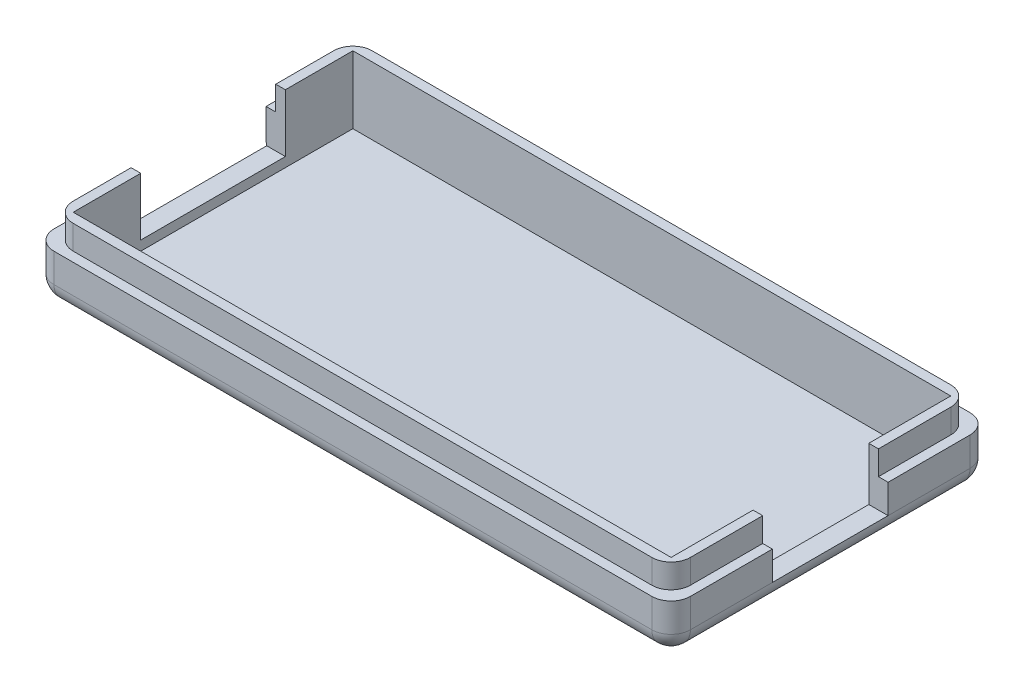
from build123d import *

# Parameters (mm, degrees)
SKETCH1_W           = 66
SKETCH1_H           = 33
BOSS_EXTRUDE1_DEPTH = 5
SKETCH2_W           = 64
SKETCH2_H           = 31
BOSS_EXTRUDE2_DEPTH = 2.5
SKETCH3_W           = 62
SKETCH3_H           = 29
CUT_EXTRUDE1_DEPTH  = 7
FILLET1_R           = 2
FILLET2_R           = 2
SKETCH4_W           = 12
SKETCH4_H           = 2.5
CUT_EXTRUDE2_DEPTH  = 7
SKETCH10_W          = 12
SKETCH10_H          = 3
CUT_EXTRUDE3_DEPTH  = 7
SKETCH11_W          = 15
SKETCH11_H          = 2.5
CUT_EXTRUDE4_DEPTH  = 7
SKETCH12_W          = 15
SKETCH12_H          = 3.5
CUT_EXTRUDE5_DEPTH  = 7


with BuildPart() as part:
    # Sketch1 → Boss-Extrude1 (new body)
    with BuildSketch(Plane(origin=(0, 0, 0), x_dir=(1, 0, 0), z_dir=(0, 1, 0))):
        with Locations((33, 16.5)):
            Rectangle(SKETCH1_W, SKETCH1_H)
    extrude(amount=BOSS_EXTRUDE1_DEPTH)

    # Sketch2 → Boss-Extrude2 (add)
    with BuildSketch(Plane(origin=(0, 5, 0), x_dir=(1, 0, 0), z_dir=(0, 1, 0))):
        with Locations((33, 16.5)):
            Rectangle(SKETCH2_W, SKETCH2_H)
    extrude(amount=BOSS_EXTRUDE2_DEPTH)

    # Sketch3 → Cut-Extrude1 (cut)
    with BuildSketch(Plane(origin=(0, 7.5, 0), x_dir=(1, 0, 0), z_dir=(0, 1, 0))):
        with Locations((33, 16.5)):
            Rectangle(SKETCH3_W, SKETCH3_H)
    extrude(amount=-CUT_EXTRUDE1_DEPTH, mode=Mode.SUBTRACT)

    # Fillet1
    fillet1_edges = [part.edges().sort_by_distance(p)[0] for p in [
        (33, 0, -33),
        (66, 0, -16.5),
        (33, 0, 0),
        (0, 0, -16.5),
        (0, 2.5, -33),
        (66, 2.5, -33),
        (66, 2.5, 0),
        (0, 2.5, 0),
    ]]
    fillet(fillet1_edges, radius=FILLET1_R)

    # Fillet2
    fillet2_edges = [part.edges().sort_by_distance(p)[0] for p in [
        (1, 6.25, -32),
        (1, 6.25, -1),
        (65, 6.25, -1),
        (65, 6.25, -32),
    ]]
    fillet(fillet2_edges, radius=FILLET2_R)

    # Sketch4 → Cut-Extrude2 (cut)
    with BuildSketch(Plane(origin=(65, 0, 0), x_dir=(0, 0, -1), z_dir=(1, 0, 0))):
        with Locations((16.5, 6.25)):
            Rectangle(SKETCH4_W, SKETCH4_H)
    extrude(amount=-CUT_EXTRUDE2_DEPTH, mode=Mode.SUBTRACT)

    # Sketch10 → Cut-Extrude3 (cut)
    with BuildSketch(Plane(origin=(66, 0, 0), x_dir=(0, 0, -1), z_dir=(1, 0, 0))):
        with Locations((16.5, 3.5)):
            Rectangle(SKETCH10_W, SKETCH10_H)
    extrude(amount=-CUT_EXTRUDE3_DEPTH, mode=Mode.SUBTRACT)

    # Sketch11 → Cut-Extrude4 (cut)
    with BuildSketch(Plane.ZY.offset(-1)):
        with Locations((-16.5, 6.25)):
            Rectangle(SKETCH11_W, SKETCH11_H)
    extrude(amount=-CUT_EXTRUDE4_DEPTH, mode=Mode.SUBTRACT)

    # Sketch12 → Cut-Extrude5 (cut)
    with BuildSketch(Plane.ZY):
        with Locations((-16.5, 3.25)):
            Rectangle(SKETCH12_W, SKETCH12_H)
    extrude(amount=-CUT_EXTRUDE5_DEPTH, mode=Mode.SUBTRACT)


solid = part.part
